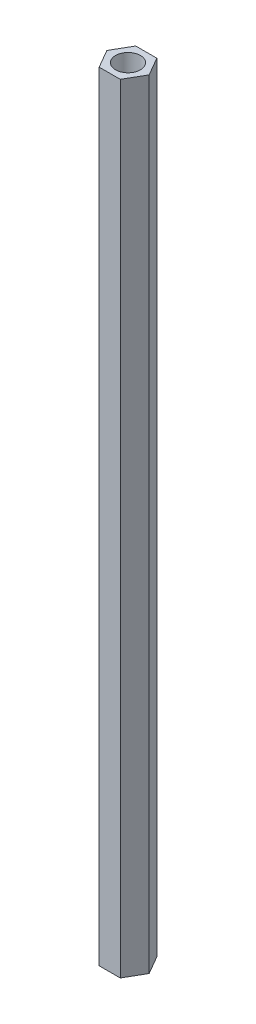
from build123d import *

# Parameters (mm, degrees)
EXTRUDE_1_DEPTH     = 100
SKETCH_2_R          = 1.6
CUT_EXTRUDE_1_DEPTH = 101


with BuildPart() as part:
    # 草图1 → 凸台-拉伸1 (new body)
    with BuildSketch(Plane(origin=(0, 0, 0), x_dir=(1, 0, 0), z_dir=(0, 1, 0))):
        Polygon((2.713546265, 0), (1.356773133, 2.35), (-1.356773133, 2.35), (-2.713546265, 0), (-1.356773133, -2.35), (1.356773133, -2.35), align=None)
    extrude(amount=EXTRUDE_1_DEPTH)

    # 草图2 → 切除-拉伸1 (cut, through all)
    with BuildSketch(Plane(origin=(0, 100, 0), x_dir=(1, 0, 0), z_dir=(0, 1, 0))):
        Circle(SKETCH_2_R)
    extrude(amount=-CUT_EXTRUDE_1_DEPTH, mode=Mode.SUBTRACT)


solid = part.part
